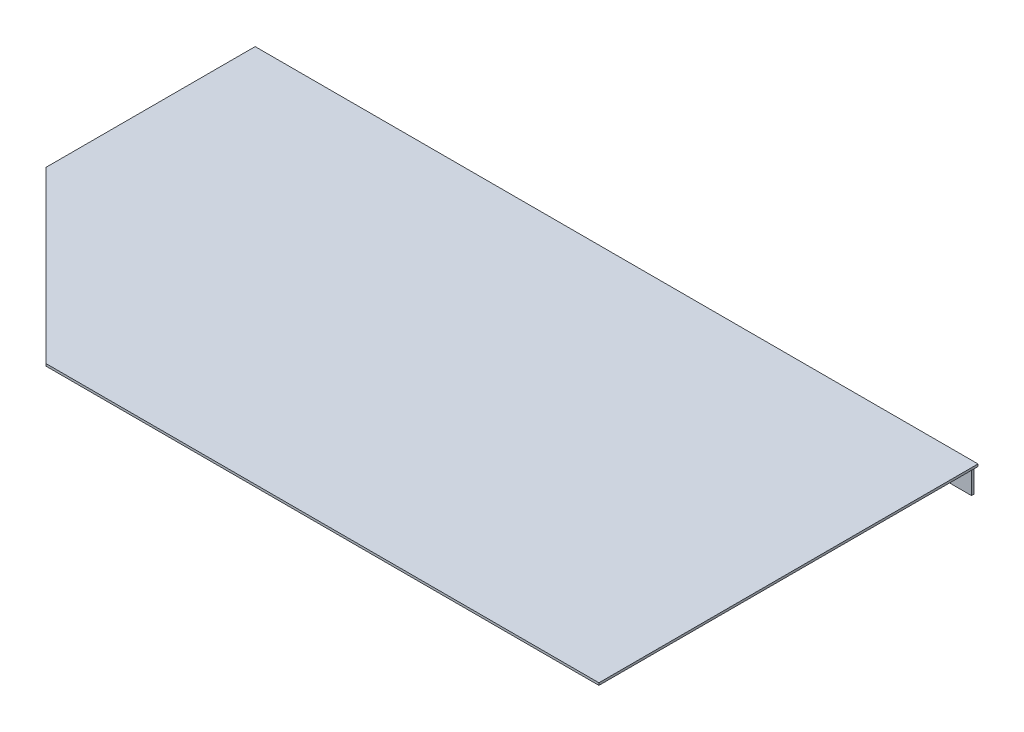
from build123d import *

# Parameters (mm, degrees)
SZKIC2_W                    = 553
SZKIC2_H                    = 1.75
DODANIE_WYCI_GNI_CIE1_DEPTH = 290
WYTNIJ_WYCI_GNI_CIE1_DEPTH  = 10
SZKIC7_W                    = 548
SZKIC7_H                    = 1.75
DODANIE_WYCI_GNI_CIE4_DEPTH = 20


with BuildPart() as part:
    # Szkic2 → Dodanie-wyciągnięcie1 (new body)
    with BuildSketch(Plane.XY):
        with Locations((0, -0.875)):
            Rectangle(SZKIC2_W, SZKIC2_H)
    extrude(amount=DODANIE_WYCI_GNI_CIE1_DEPTH)

    # Szkic3 → Wytnij-wyciągnięcie1 (cut)
    with BuildSketch(Plane(origin=(0, 0, 0), x_dir=(1, 0, 0), z_dir=(0, 1, 0))):
        Polygon((-276.5, -290), (-276.5, -160), (-146.5, -290), align=None)
    extrude(amount=-WYTNIJ_WYCI_GNI_CIE1_DEPTH, mode=Mode.SUBTRACT)

    # Szkic7 → Dodanie-wyciągnięcie4 (add)
    with BuildSketch(Plane.XZ.offset(1.75)):
        with Locations((-0.75, 0.875)):
            Rectangle(SZKIC7_W, SZKIC7_H)
    extrude(amount=DODANIE_WYCI_GNI_CIE4_DEPTH)


solid = part.part
